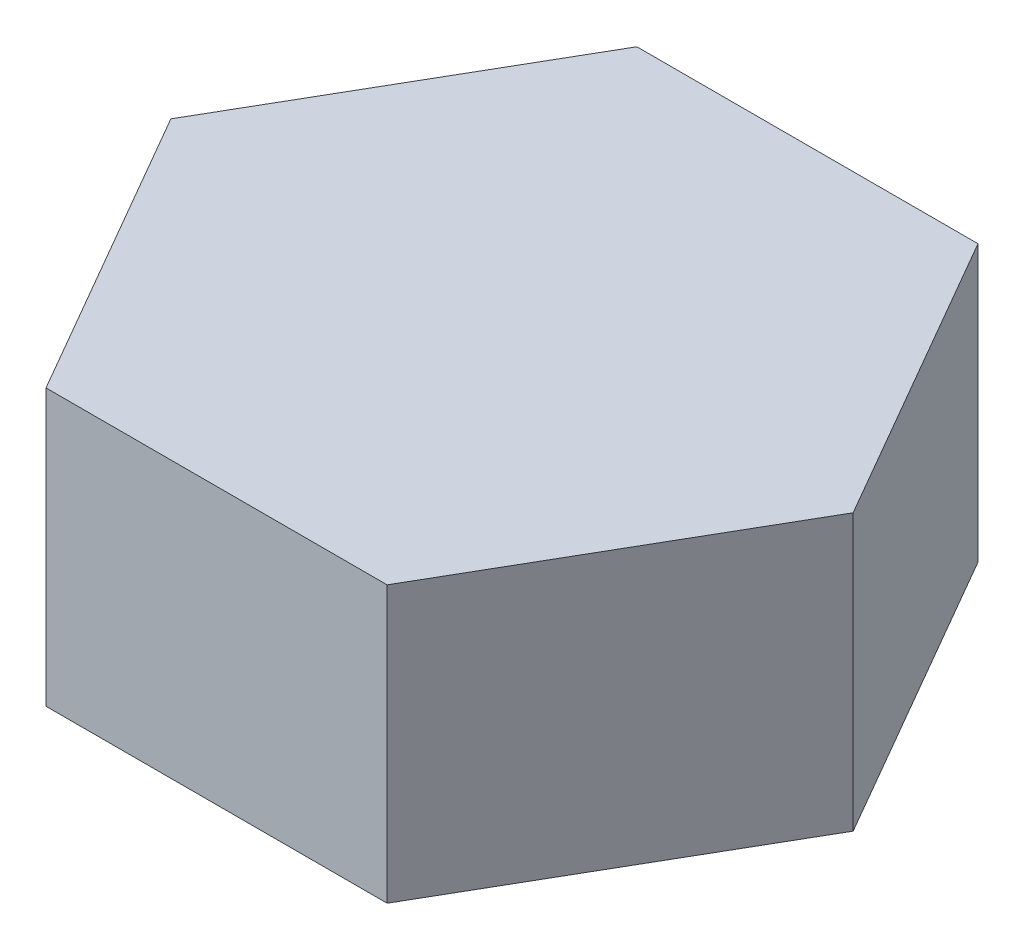
from build123d import *

# Parameters (mm, degrees)
BOSS_EXTRUDE1_DEPTH = 2.1


with BuildPart() as part:
    # Sketch1 → Boss-Extrude1 (new body)
    with BuildSketch(Plane(origin=(0, 0, 0), x_dir=(1, 0, 0), z_dir=(0, 1, 0))):
        Polygon((2.59807621, 0), (1.299038105, 2.249999999), (-1.299038105, 2.249999999), (-2.59807621, 0), (-1.299038105, -2.249999999), (1.299038105, -2.249999999), align=None)
    extrude(amount=BOSS_EXTRUDE1_DEPTH)


solid = part.part
